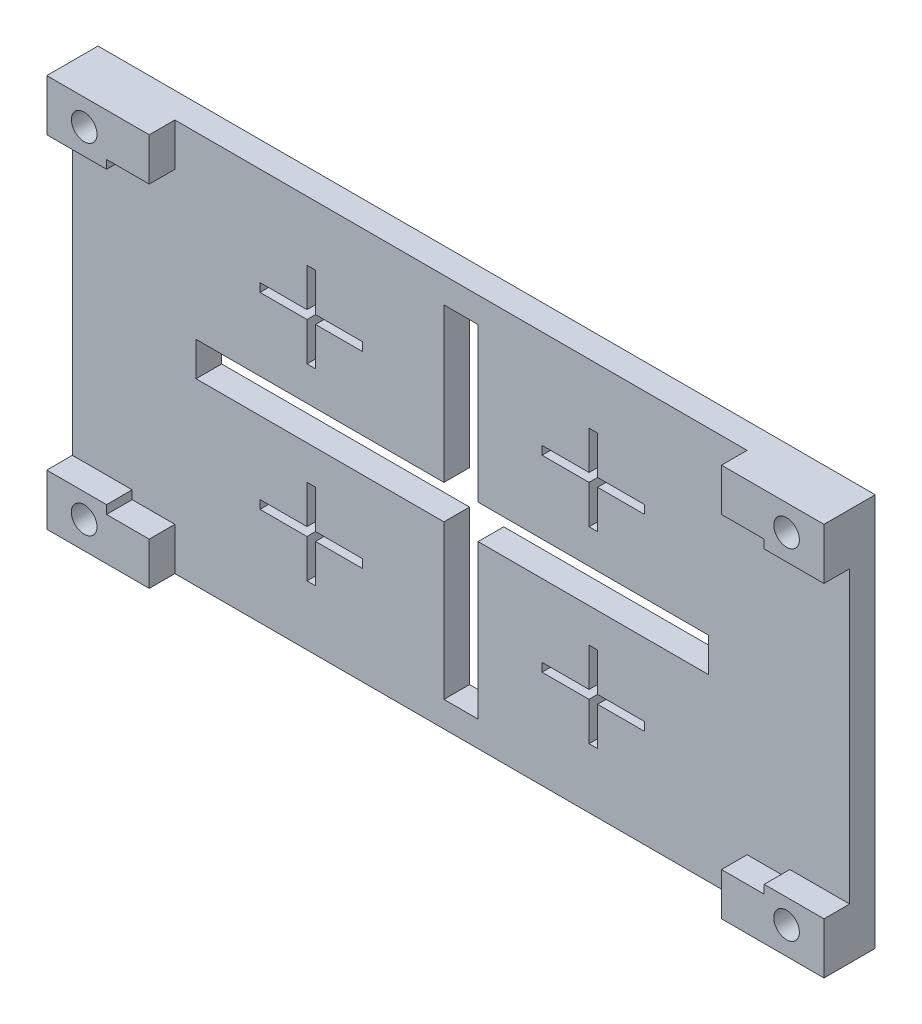
from build123d import *

# Parameters (mm, degrees)
BOSS_EXTRUDE1_DEPTH = 3
BOSS_EXTRUDE2_DEPTH = 3
SKETCH5_R           = 1.5
CUT_EXTRUDE7_DEPTH  = 94.625942534
SKETCH5_26_R        = 1.5
CUT_EXTRUDE8_DEPTH  = 94.625942534


with BuildPart() as part:
    # Sketch1 → Boss-Extrude1 (new body)
    with BuildSketch(Plane.XY):
        Polygon((-7, 40.912310071), (-7, 30.912310071), (-7, 4.912310071), (-7, -5.087689929), (5, -5.087689929), (69.955466391, -5.087689929), (84, -5.087689929), (84, 4.912310071), (84, 30.912310071), (84, 40.912310071), (69.955466391, 40.912310071), (5, 40.912310071), align=None)
        Polygon((20.466599793, 11.912310071), (21.466599793, 11.912310071), (21.466599793, 7.412310071), (26.966599793, 7.412310071), (26.966599793, 6.412310071), (21.466599793, 6.412310071), (21.466599793, 1.912310071), (20.466599793, 1.912310071), (20.466599793, 6.412310071), (14.966599793, 6.412310071), (14.966599793, 7.412310071), (20.466599793, 7.412310071), align=None, mode=Mode.SUBTRACT)
        Polygon((53.488866598, 7.412310071), (53.488866598, 11.912310071), (54.488866598, 11.912310071), (54.488866598, 7.412310071), (59.988866598, 7.412310071), (59.988866598, 6.412310071), (54.488866598, 6.412310071), (54.488866598, 1.912310071), (53.488866598, 1.912310071), (53.488866598, 6.412310071), (47.988866598, 6.412310071), (47.988866598, 7.412310071), align=None, mode=Mode.SUBTRACT)
        Polygon((40.5, 37.912310071), (40.5, 19.912310071), (67.477733195, 19.912310071), (67.477733195, 15.912310071), (40.5, 15.912310071), (40.5, -2.087689929), (36.5, -2.087689929), (36.5, 15.912310071), (7.477733195, 15.912310071), (7.477733195, 19.912310071), (36.5, 19.912310071), (36.5, 37.912310071), align=None, mode=Mode.SUBTRACT)
        Polygon((21.466599793, 28.412310071), (21.466599793, 23.912310071), (20.466599793, 23.912310071), (20.466599793, 28.412310071), (14.966599793, 28.412310071), (14.966599793, 29.412310071), (20.466599793, 29.412310071), (20.466599793, 33.912310071), (21.466599793, 33.912310071), (21.466599793, 29.412310071), (26.966599793, 29.412310071), (26.966599793, 28.412310071), align=None, mode=Mode.SUBTRACT)
        Polygon((54.488866598, 23.912310071), (53.488866598, 23.912310071), (53.488866598, 28.412310071), (47.988866598, 28.412310071), (47.988866598, 29.412310071), (53.488866598, 29.412310071), (53.488866598, 33.912310071), (54.488866598, 33.912310071), (54.488866598, 29.412310071), (59.988866598, 29.412310071), (59.988866598, 28.412310071), (54.488866598, 28.412310071), align=None, mode=Mode.SUBTRACT)
    extrude(amount=BOSS_EXTRUDE1_DEPTH)

    # Sketch3 → Boss-Extrude2 (add)
    with BuildSketch(Plane.XY.offset(3)):
        Polygon((-7, -5.087689929), (-7, 0.912310071), (0, 0.912310071), (0, -0.087689929), (5, -0.087689929), (5, -5.087689929), align=None)
        Polygon((0, 35.912310071), (5, 35.912310071), (5, 40.912310071), (-7, 40.912310071), (-7, 34.912310071), (0, 34.912310071), align=None)
        Polygon((77, -0.087689929), (72, -0.087689929), (72, -5.087689929), (84, -5.087689929), (84, 0.912310071), (77, 0.912310071), align=None)
        Polygon((77, 34.912310071), (77, 35.912310071), (72, 35.912310071), (72, 40.912310071), (84, 40.912310071), (84, 34.912310071), align=None)
    extrude(amount=BOSS_EXTRUDE2_DEPTH)

    # Sketch5 → Cut-Extrude7 (cut, through all)
    with BuildSketch(Plane.XY):
        with Locations((79.617691454, -1.9)):
            Circle(SKETCH5_R)
    extrude(amount=CUT_EXTRUDE7_DEPTH, mode=Mode.SUBTRACT)

    # Sketch5_26 → Cut-Extrude8 (cut, through all)
    with BuildSketch(Plane.XY):
        with Locations((-2.617691454, 37.9)):
            Circle(SKETCH5_26_R)
        with Locations((-2.617691454, -1.9)):
            Circle(SKETCH5_26_R)
        with Locations((79.617691454, 37.9)):
            Circle(SKETCH5_26_R)
    extrude(amount=CUT_EXTRUDE8_DEPTH, mode=Mode.SUBTRACT)


solid = part.part
